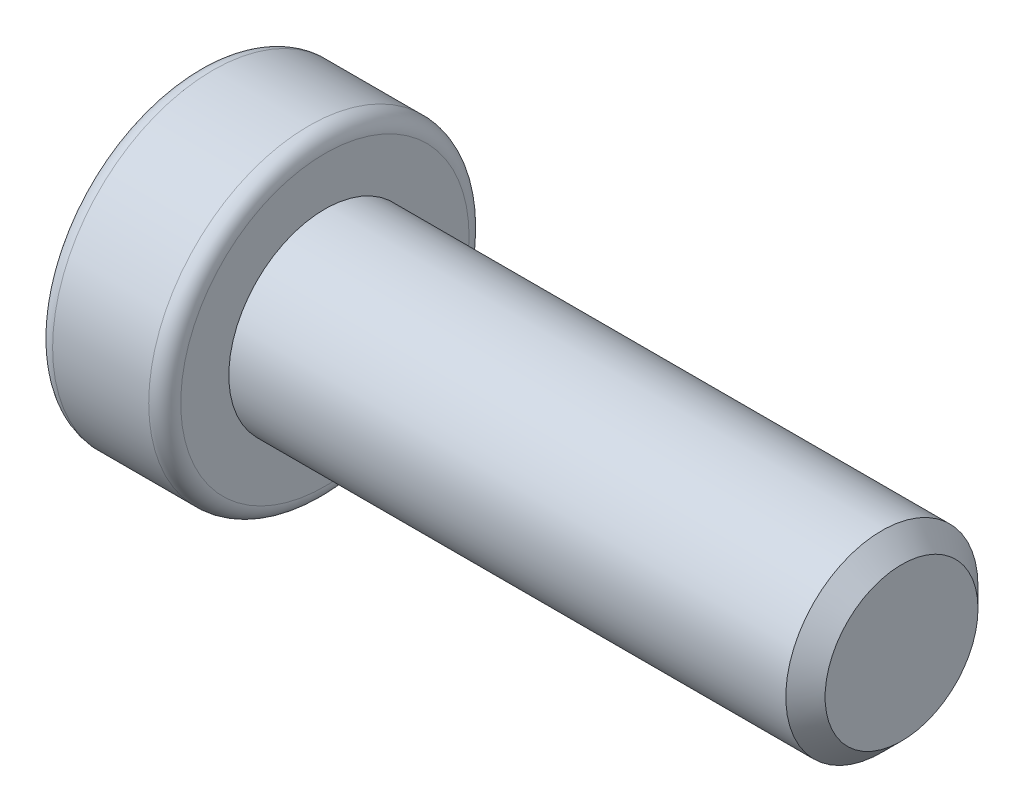
from build123d import *

# Parameters (mm, degrees)
CUT_EXTRUDE1_DEPTH = 2.5


with BuildPart() as part:
    # Sketch1 → Revolve1 (revolve)
    with BuildSketch(Plane.XY):
        with BuildLine():
            Line((2.5, 0), (1, 1.5))
            Line((1, 1.5), (-0.5, 1.5))
            Line((-0.5, 1.5), (-1.5, 2.5))
            Line((-1.5, 2.5), (-3.613248654, 2.5))
            Line((-3.613248654, 2.5), (-4, 2.886751346))
            Line((-4, 2.886751346), (-4, 4.5))
            ThreePointArc((-4, 4.5), (-3.853553391, 4.853553391), (-3.5, 5))
            Line((-3.5, 5), (-0.5, 5))
            ThreePointArc((-0.5, 5), (-0.146446609, 4.853553391), (0, 4.5))
            Line((0, 4.5), (0, 3))
            Line((0, 3), (17.3865, 3))
            Line((17.3865, 3), (18, 2.3865))
            Line((18, 2.3865), (18, 0))
            Line((18, 0), (2.5, 0))
        make_face()
    revolve(axis=Axis((18, 0, 0), (-1, 0, 0)))

    # Sketch2 → Cut-Extrude1 (cut)
    with BuildSketch(Plane(origin=(-4, 0, 0), x_dir=(0, 0, -1), z_dir=(1, 0, 0))):
        Polygon((-2.5, -1.443375673), (0, -2.886751346), (2.5, -1.443375673), (2.5, 1.443375673), (0, 2.886751346), (-2.5, 1.443375673), align=None)
    extrude(amount=CUT_EXTRUDE1_DEPTH, mode=Mode.SUBTRACT)


solid = part.part
